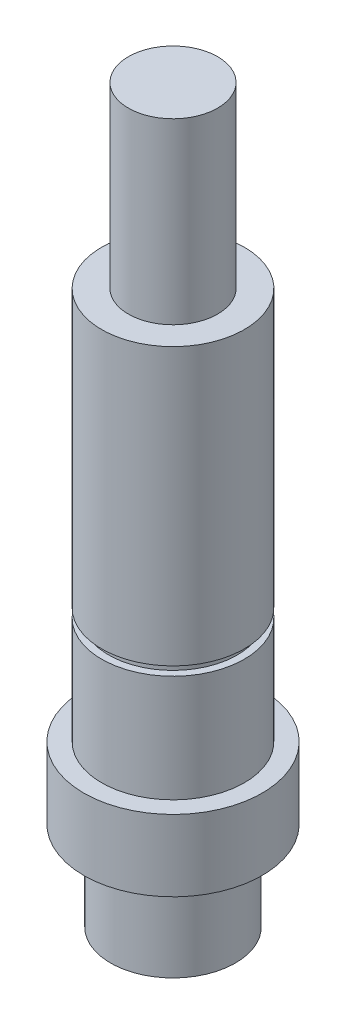
from build123d import *


with BuildPart() as part:
    # Sketch2 → Revolve1 (revolve)
    with BuildSketch(Plane.XY):
        Polygon((-2.4451521, 34.195402299), (-2.4451521, 24.195402299), (-3.9451521, 24.195402299), (-3.9451521, 8.695402299), (-3.5451521, 8.695402299), (-3.5451521, 8.195402299), (-3.9451521, 8.195402299), (-3.9451521, 2.195402299), (-4.9451521, 2.195402299), (-4.9451521, -1.804597701), (-3.4451521, -1.804597701), (-3.4451521, -6.804597701), (0.0548479, -6.804597701), (0.0548479, 34.195402299), align=None)
    revolve(axis=Axis((0.0548479, -6.804597701, 0), (0, 1, 0)))


solid = part.part
